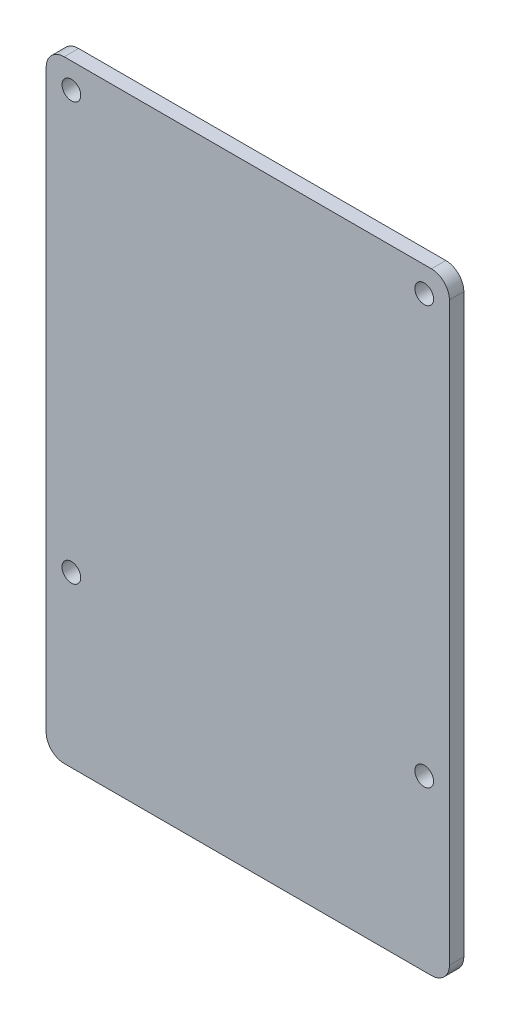
from build123d import *

# Parameters (mm, degrees)
SKETCH_1_R      = 1.3
EXTRUDE_1_DEPTH = 2


with BuildPart() as part:
    # 草图1 → 凸台-拉伸1 (new body)
    with BuildSketch(Plane.XY):
        with BuildLine():
            Line((-1, 3.5), (50, 3.5))
            ThreePointArc((50, 3.5), (51.767766953, 2.767766953), (52.5, 1))
            Line((52.5, 1), (52.5, -79))
            ThreePointArc((52.5, -79), (51.767766953, -80.767766953), (50, -81.5))
            Line((50, -81.5), (-1, -81.5))
            ThreePointArc((-1, -81.5), (-2.767766953, -80.767766953), (-3.5, -79))
            Line((-3.5, -79), (-3.5, 1))
            ThreePointArc((-3.5, 1), (-2.767766953, 2.767766953), (-1, 3.5))
        make_face()
        with Locations((49, 0)):
            Circle(SKETCH_1_R, mode=Mode.SUBTRACT)
        with Locations((49, -58)):
            Circle(SKETCH_1_R, mode=Mode.SUBTRACT)
        with Locations((0, -58)):
            Circle(SKETCH_1_R, mode=Mode.SUBTRACT)
        Circle(SKETCH_1_R, mode=Mode.SUBTRACT)
    extrude(amount=EXTRUDE_1_DEPTH)


solid = part.part
